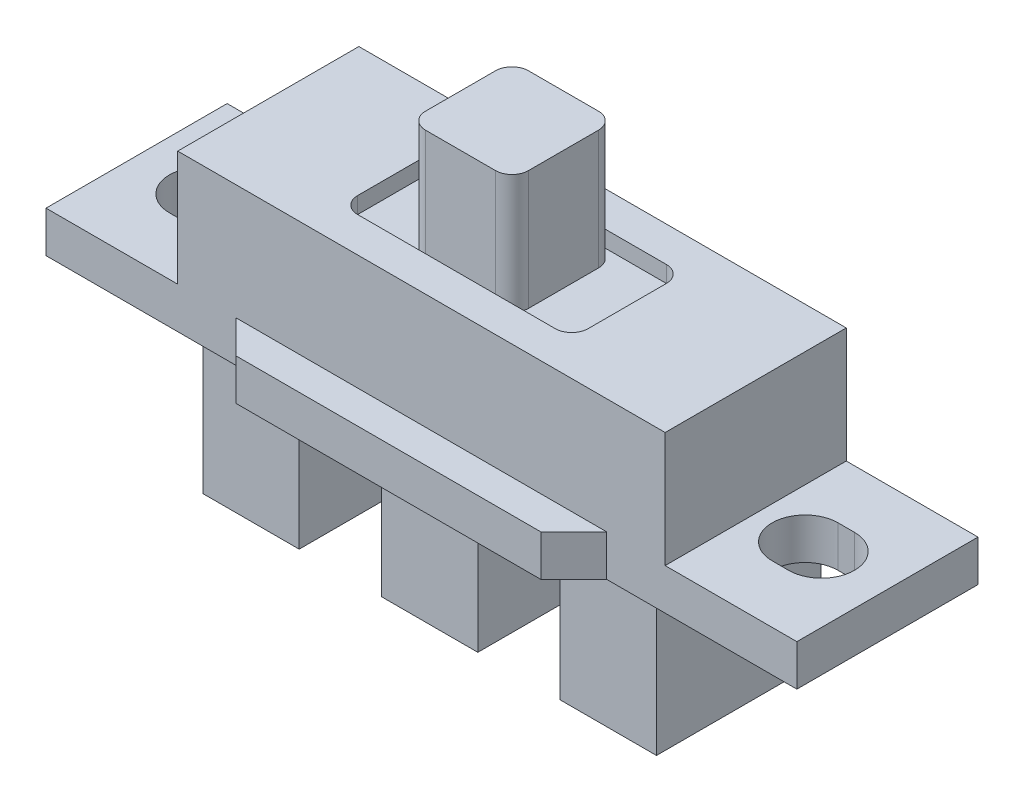
from build123d import *

# Parameters (mm, degrees)
SKETCH1_W               = 29.6
SKETCH1_H               = 11
BOSS_EXTRUDE1_DEPTH     = 7
SKETCH2_W               = 6.25
SKETCH2_H               = 6.25
BOSS_EXTRUDE2_DEPTH     = 6.25
SKETCH3_W               = 7.999999319
SKETCH3_H               = 11
BOSS_EXTRUDE3_DEPTH     = 2.5
CUT_EXTRUDE1_DEPTH      = 14.25
CUT_EXTRUDE1_DEPTH_BACK = 3.5
SKETCH5_W               = 5.85
SKETCH5_H               = 10
BOSS_EXTRUDE4_DEPTH     = 8.25
CUT_EXTRUDE2_DEPTH      = 3
SKETCH7_W               = 14
SKETCH7_H               = 6.75
SKETCH7_W_2             = 6.25
SKETCH7_H_2             = 6.25
CUT_EXTRUDE3_DEPTH      = 1
FILLET1_R               = 1
FILLET2_R               = 1


with BuildPart() as part:
    # Sketch1 → Boss-Extrude1 (new body)
    with BuildSketch(Plane(origin=(0, 0, 0), x_dir=(1, 0, 0), z_dir=(0, 1, 0))):
        Rectangle(SKETCH1_W, SKETCH1_H)
    extrude(amount=BOSS_EXTRUDE1_DEPTH)

    # Sketch2 → Boss-Extrude2 (add)
    with BuildSketch(Plane(origin=(0, 7, 0), x_dir=(1, 0, 0), z_dir=(0, 1, 0))):
        Rectangle(SKETCH2_W, SKETCH2_H)
    extrude(amount=BOSS_EXTRUDE2_DEPTH)

    # Sketch3 → Boss-Extrude3 (add)
    with BuildSketch(Plane.XZ):
        with Locations((-18.79999966, 0)):
            Rectangle(SKETCH3_W, SKETCH3_H)
        Polygon((-14.8, 5.5), (-14.8, -5.5), (-11.25, -5.5), (11.25, -5.5), (14.8, -5.5), (14.8, 5.5), (11.25, 5.5), (0, 5.5), (-11.25, 5.5), align=None)
        Polygon((-9.25, 7.5), (-11.25, 5.5), (0, 5.5), (0, 7.5), align=None)
        Polygon((0, 7.5), (0, 5.5), (11.25, 5.5), (9.25, 7.5), align=None)
        with Locations((18.79999966, 0)):
            Rectangle(SKETCH3_W, SKETCH3_H)
        Polygon((11.25, -5.5), (-11.25, -5.5), (-9.25, -7.5), (0, -7.5), (9.25, -7.5), align=None)
    extrude(amount=BOSS_EXTRUDE3_DEPTH)

    # Sketch4 → Cut-Extrude1 (cut, two sides)
    with BuildSketch(Plane(origin=(0, 0, 0), x_dir=(1, 0, 0), z_dir=(0, 1, 0))) as cut_extrude1_sk:
        with BuildLine():
            Line((-18.799999319, 2), (-17.799999319, 2))
            ThreePointArc((-17.799999319, 2), (-15.799999319, 0), (-17.799999319, -2))
            Line((-17.799999319, -2), (-18.799999319, -2))
            ThreePointArc((-18.799999319, -2), (-20.799999319, 0), (-18.799999319, 2))
        make_face()
        with BuildLine():
            Line((18.799999319, 2), (17.799999319, 2))
            ThreePointArc((17.799999319, 2), (15.799999319, 0), (17.799999319, -2))
            Line((17.799999319, -2), (18.799999319, -2))
            ThreePointArc((18.799999319, -2), (20.799999319, 0), (18.799999319, 2))
        make_face()
    extrude(amount=CUT_EXTRUDE1_DEPTH, mode=Mode.SUBTRACT)
    extrude(cut_extrude1_sk.sketch, amount=-CUT_EXTRUDE1_DEPTH_BACK, mode=Mode.SUBTRACT)

    # Sketch5 → Boss-Extrude4 (add)
    with BuildSketch(Plane.XZ.offset(2.5)):
        Rectangle(SKETCH5_W, SKETCH5_H)
        with Locations((10.85, 0)):
            Rectangle(SKETCH5_W, SKETCH5_H)
        with Locations((-10.85, 0)):
            Rectangle(SKETCH5_W, SKETCH5_H)
    extrude(amount=BOSS_EXTRUDE4_DEPTH)

    # Sketch6 → Cut-Extrude2 (cut)
    with BuildSketch(Plane.XZ.offset(10.75)):
        with BuildLine():
            Line((-2, -3), (2, -3))
            ThreePointArc((2, -3), (0, -1), (-2, -3))
        make_face()
        with BuildLine():
            Line((8.85, -3), (12.85, -3))
            ThreePointArc((12.85, -3), (10.85, -1), (8.85, -3))
        make_face()
        with BuildLine():
            Line((-12.85, -3), (-8.85, -3))
            ThreePointArc((-8.85, -3), (-10.85, -1), (-12.85, -3))
        make_face()
    extrude(amount=-CUT_EXTRUDE2_DEPTH, mode=Mode.SUBTRACT)

    # Sketch7 → Cut-Extrude3 (cut)
    with BuildSketch(Plane(origin=(0, 7, 0), x_dir=(1, 0, 0), z_dir=(0, 1, 0))):
        Rectangle(SKETCH7_W, SKETCH7_H)
        Rectangle(SKETCH7_W_2, SKETCH7_H_2, mode=Mode.SUBTRACT)
    extrude(amount=-CUT_EXTRUDE3_DEPTH, mode=Mode.SUBTRACT)

    # Fillet1
    fillet1_edges = [part.edges().sort_by_distance(p)[0] for p in [
        (7, 6.5, 3.375),
        (-7, 6.5, 3.375),
        (-7, 6.5, -3.375),
        (7, 6.5, -3.375),
    ]]
    fillet(fillet1_edges, radius=FILLET1_R)

    # Fillet2
    fillet2_edges = [part.edges().sort_by_distance(p)[0] for p in [
        (3.125, 9.625, 3.125),
        (3.125, 9.625, -3.125),
        (-3.125, 9.625, -3.125),
        (-3.125, 9.625, 3.125),
    ]]
    fillet(fillet2_edges, radius=FILLET2_R)


solid = part.part
